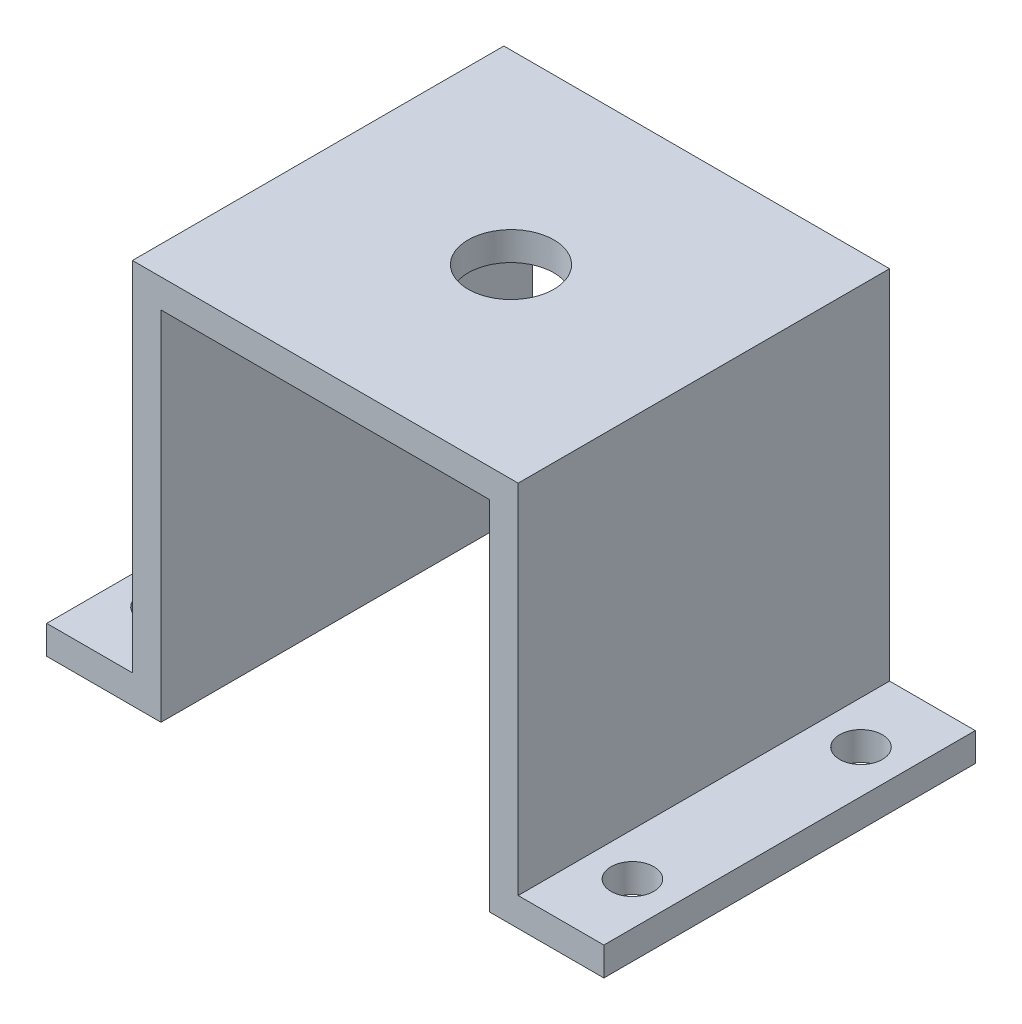
from build123d import *

# Parameters (mm, degrees)
EXTRU_MINCE1_DEPTH = 26
EXTRUSION1_REACH   = 50.642
ESQUISSE4_R        = 3
EXTRUSION2_REACH   = 49.56
ESQUISSE5_R        = 1.5


with BuildPart() as part:
    # Esquisse1 → Extru.-Mince1 (new body)
    with BuildSketch(Plane.XY):
        Polygon((-8, 0), (0, 0), (0, 25), (23, 25), (23, 0), (31, 0), (31, 2), (25, 2), (25, 27), (-2, 27), (-2, 2), (-8, 2), align=None)
    extrude(amount=EXTRU_MINCE1_DEPTH)

    # Esquisse4 → Extrusion1 (cut, up to next)
    with BuildSketch(Plane(origin=(0, 27, 0), x_dir=(1, 0, 0), z_dir=(0, 1, 0)), mode=Mode.PRIVATE) as extrusion1_sk1:
        with Locations((11.5, -13)):
            Circle(ESQUISSE4_R)
    extrusion1_tool1 = extrude(extrusion1_sk1.sketch, amount=-EXTRUSION1_REACH, mode=Mode.PRIVATE) & part.part
    add(extrusion1_tool1.solids().sort_by_distance((11.5, 27, 13))[0], mode=Mode.SUBTRACT)

    # Esquisse5 → Extrusion2 (cut, up to next)
    with BuildSketch(Plane(origin=(0, 2, 0), x_dir=(1, 0, 0), z_dir=(0, 1, 0)), mode=Mode.PRIVATE) as extrusion2_sk1:
        with Locations((-5, -21)):
            Circle(ESQUISSE5_R)
    extrusion2_tool1 = extrude(extrusion2_sk1.sketch, amount=-EXTRUSION2_REACH, mode=Mode.PRIVATE) & part.part
    # Esquisse5 → Extrusion2 (cut, up to next)
    with BuildSketch(Plane(origin=(0, 2, 0), x_dir=(1, 0, 0), z_dir=(0, 1, 0)), mode=Mode.PRIVATE) as extrusion2_sk2:
        with Locations((-5, -5)):
            Circle(ESQUISSE5_R)
    extrusion2_tool2 = extrude(extrusion2_sk2.sketch, amount=-EXTRUSION2_REACH, mode=Mode.PRIVATE) & part.part
    extrusion2_1 = extrusion2_tool1.solids().sort_by_distance((-5, 2, 21))[0]
    add(extrusion2_1, mode=Mode.SUBTRACT)
    extrusion2_2 = extrusion2_tool2.solids().sort_by_distance((-5, 2, 5))[0]
    add(extrusion2_2, mode=Mode.SUBTRACT)
    extrusion2 = extrusion2_1 + extrusion2_2  # Extrusion2 as one shape, for the pattern or mirror that repeats it

    # Symétrie1: Extrusion2 across plane
    add(extrusion2.mirror(Plane(origin=(11.5, 27, 26), x_dir=(0, 0, 1), z_dir=(-1, 0, 0))), mode=Mode.SUBTRACT)


solid = part.part
